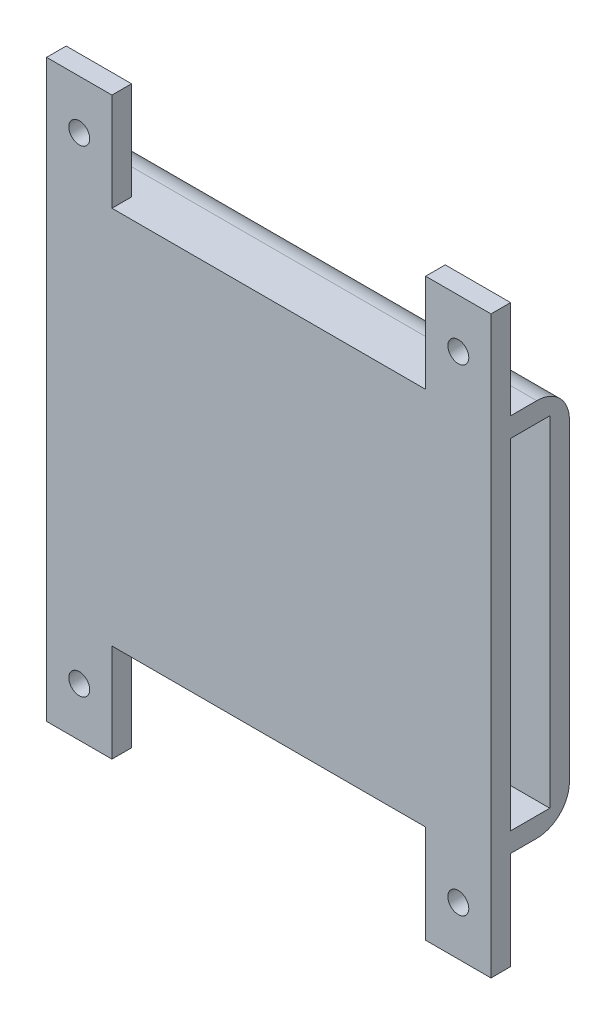
from build123d import *

# Parameters (mm, degrees)
ESQUISSE1_W             = 68
ESQUISSE1_H             = 58
BOSS_EXTRU_1_DEPTH      = 3
BOSS_EXTRU_2_DEPTH      = 9
ESQUISSE4_W             = 3
ESQUISSE4_H             = 52
BOSS_EXTRU_3_DEPTH      = 65
ESQUISSE6_W             = 10
ESQUISSE6_H             = 3
BOSS_EXTRU_4_DEPTH      = 15
ESQUISSE7_R             = 1.6
ENL_V_MAT_EXTRU_1_DEPTH = 3
CONG_1_R                = 5


with BuildPart() as part:
    # Esquisse1 → Boss.-Extru.1 (new body)
    with BuildSketch(Plane.XY):
        Rectangle(ESQUISSE1_W, ESQUISSE1_H)
    extrude(amount=BOSS_EXTRU_1_DEPTH)

    # Esquisse2 → Boss.-Extru.2 (add)
    with BuildSketch(Plane.XY.offset(3)):
        Polygon((34, 26), (34, 29), (-34, 29), (-34, -29), (34, -29), (34, -26), (-31, -26), (-31, 26), align=None)
    extrude(amount=BOSS_EXTRU_2_DEPTH)

    # Esquisse4 → Boss.-Extru.3 (add)
    with BuildSketch(Plane(origin=(-31, 0, 0), x_dir=(0, 0, -1), z_dir=(1, 0, 0))):
        with Locations((-10.5, 0)):
            Rectangle(ESQUISSE4_W, ESQUISSE4_H)
    extrude(amount=BOSS_EXTRU_3_DEPTH)

    # Esquisse6 → Boss.-Extru.4 (add)
    with BuildSketch(Plane.XZ.offset(29)):
        with Locations((-29, 10.5)):
            Rectangle(ESQUISSE6_W, ESQUISSE6_H)
        with Locations((29, 10.5)):
            Rectangle(ESQUISSE6_W, ESQUISSE6_H)
    boss_extru_4 = extrude(amount=BOSS_EXTRU_4_DEPTH)

    # Esquisse7 → Enlèv. mat.-Extru.1 (cut)
    with BuildSketch(Plane.XY.offset(12)):
        with Locations((-29, -36.5)):
            Circle(ESQUISSE7_R)
        with Locations((29, -36.5)):
            Circle(ESQUISSE7_R)
    enl_v_mat_extru_1 = extrude(amount=-ENL_V_MAT_EXTRU_1_DEPTH, mode=Mode.SUBTRACT)

    # Symétrie1: Boss.-Extru.4, Enlèv. mat.-Extru.1 across plane
    add(boss_extru_4.mirror(Plane.ZX))
    add(enl_v_mat_extru_1.mirror(Plane.ZX), mode=Mode.SUBTRACT)

    # Congé1
    cong_1_edges = [part.edges().sort_by_distance(p)[0] for p in [
        (0, -29, 0),
        (-34, 0, 0),
        (0, 29, 0),
    ]]
    fillet(cong_1_edges, radius=CONG_1_R)


solid = part.part
